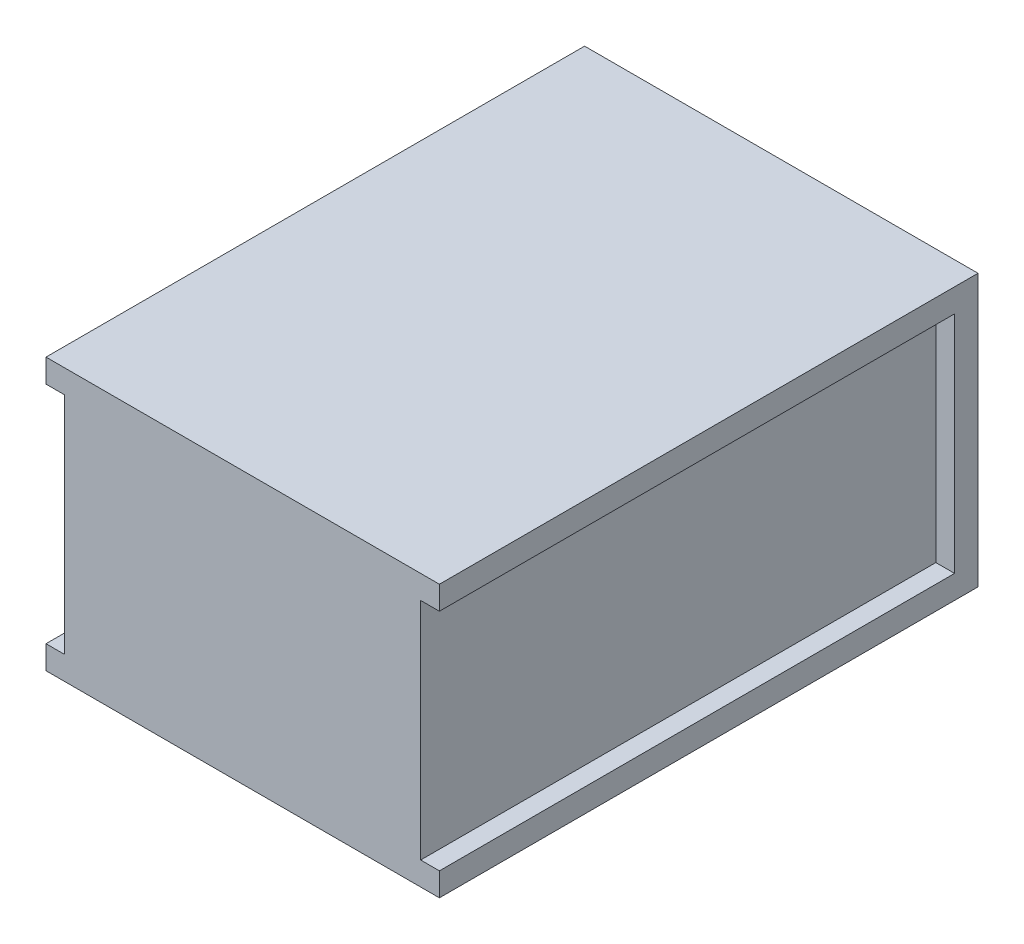
from build123d import *

# Parameters (mm, degrees)
ESQUISSE1_W             = 84
ESQUISSE1_H             = 115
BOSS_EXTRU_1_DEPTH      = 58
ESQUISSE2_W             = 110
ESQUISSE2_H             = 48
ENL_V_MAT_EXTRU_1_DEPTH = 4


with BuildPart() as part:
    # Esquisse1 → Boss.-Extru.1 (new body)
    with BuildSketch(Plane(origin=(0, 0, 0), x_dir=(1, 0, 0), z_dir=(0, 1, 0))):
        Rectangle(ESQUISSE1_W, ESQUISSE1_H)
    extrude(amount=BOSS_EXTRU_1_DEPTH)

    # Esquisse2 → Enlèv. mat.-Extru.1 (cut)
    with BuildSketch(Plane.ZY.offset(42)):
        with Locations((2.5, 29)):
            Rectangle(ESQUISSE2_W, ESQUISSE2_H)
    enl_v_mat_extru_1 = extrude(amount=-ENL_V_MAT_EXTRU_1_DEPTH, mode=Mode.SUBTRACT)

    # Symétrie1: Enlèv. mat.-Extru.1 across plane
    add(enl_v_mat_extru_1.mirror(Plane(origin=(0, 0, 0), x_dir=(0, 0, 1), z_dir=(1, 0, 0))), mode=Mode.SUBTRACT)


solid = part.part
